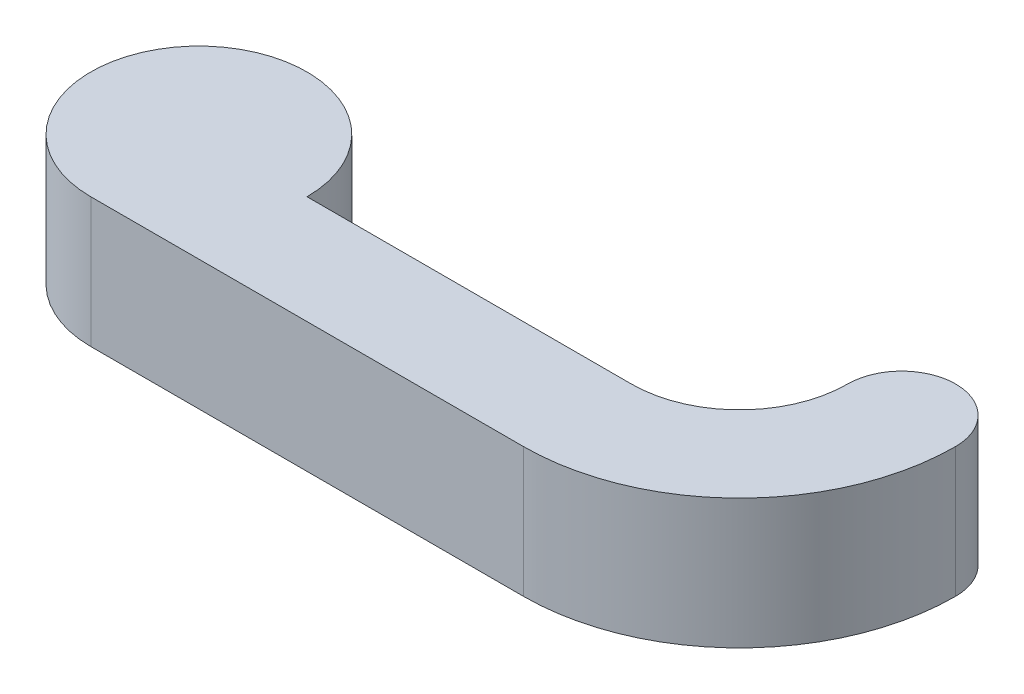
from build123d import *

# Parameters (mm, degrees)
BOSS_EXTRUDE2_DEPTH = 3
SKETCH4_R           = 3
CUT_EXTRUDE2_DEPTH  = 2.5


with BuildPart() as part:
    # Sketch1 → Boss-Extrude2 (new body, symmetric)
    with BuildSketch(Plane(origin=(0, 0, 0), x_dir=(1, 0, 0), z_dir=(0, 1, 0))):
        with BuildLine():
            ThreePointArc((5, 0), (-3.535533906, 3.535533906), (0, -5))
            Line((0, -5), (20, -5))
            ThreePointArc((20, -5), (27.071067812, -2.071067812), (30, 5))
            ThreePointArc((30, 5), (27.5, 7.5), (25, 5))
            ThreePointArc((25, 5), (23.535533906, 1.464466094), (20, 0))
            Line((20, 0), (5, 0))
        make_face()
    extrude(amount=BOSS_EXTRUDE2_DEPTH, both=True)

    # Sketch4 → Cut-Extrude2 (cut)
    with BuildSketch(Plane.XZ.offset(3)):
        Circle(SKETCH4_R)
    extrude(amount=-CUT_EXTRUDE2_DEPTH, mode=Mode.SUBTRACT)


solid = part.part
